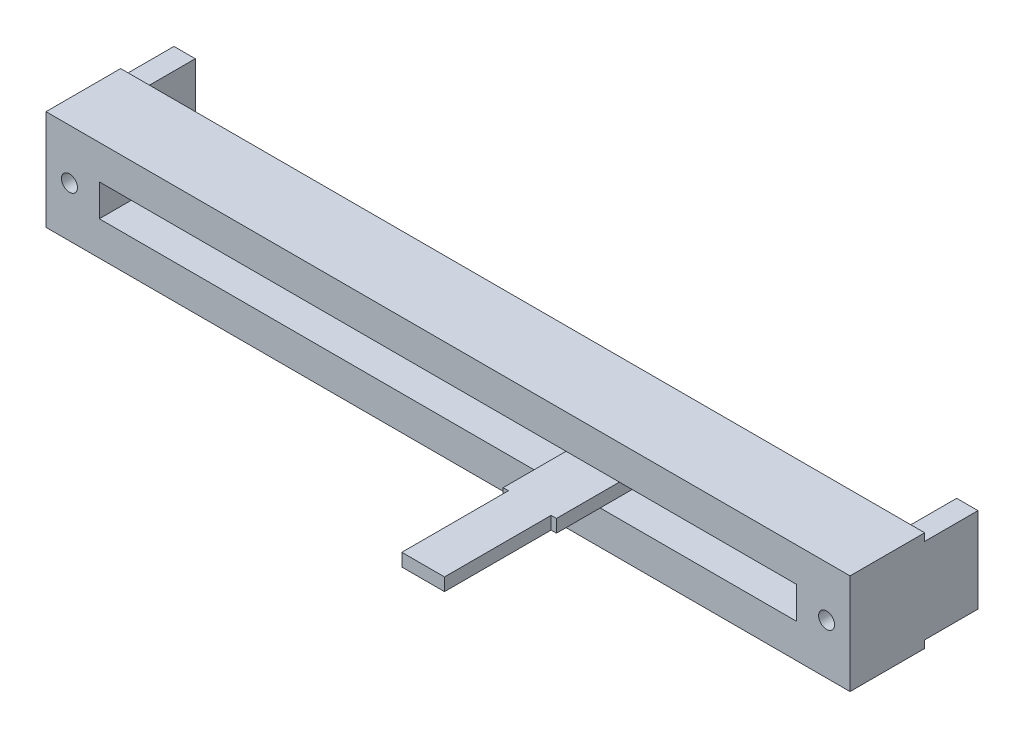
from build123d import *

# Parameters (mm, degrees)
SKETCH1_W           = 75.4
SKETCH1_H           = 9.4
BOSS_EXTRUDE1_DEPTH = 7
SKETCH2_R           = 0.75
SKETCH2_W           = 65.4
SKETCH2_H           = 3
CUT_EXTRUDE1_DEPTH  = 5
SKETCH3_W           = 2
SKETCH3_H           = 8
BOSS_EXTRUDE2_DEPTH = 5
BOSS_EXTRUDE3_DEPTH = 0.6


with BuildPart() as part:
    # Sketch1 → Boss-Extrude1 (new body)
    with BuildSketch(Plane.XY):
        Rectangle(SKETCH1_W, SKETCH1_H)
    extrude(amount=BOSS_EXTRUDE1_DEPTH)

    # Sketch2 → Cut-Extrude1 (cut)
    with BuildSketch(Plane.XY.offset(7)):
        with Locations((-35.5, 0)):
            Circle(SKETCH2_R)
        with Locations((35.5, 0)):
            Circle(SKETCH2_R)
        Rectangle(SKETCH2_W, SKETCH2_H)
    extrude(amount=-CUT_EXTRUDE1_DEPTH, mode=Mode.SUBTRACT)

    # Sketch3 → Boss-Extrude2 (add)
    with BuildSketch(Plane(origin=(0, 0, 0), x_dir=(-1, 0, 0), z_dir=(0, 0, -1))):
        with Locations((-36.7, 0)):
            Rectangle(SKETCH3_W, SKETCH3_H)
        with Locations((36.7, 0)):
            Rectangle(SKETCH3_W, SKETCH3_H)
    extrude(amount=BOSS_EXTRUDE2_DEPTH)

    # Sketch4 → Boss-Extrude3 (add, symmetric)
    with BuildSketch(Plane(origin=(0, 0, 0), x_dir=(1, 0, 0), z_dir=(0, 1, 0))):
        Polygon((10.169323516, 0), (15.169323516, 0), (15.169323516, -12), (14.669323516, -12), (14.669323516, -22), (10.669323516, -22), (10.669323516, -12), (10.169323516, -12), align=None)
    extrude(amount=BOSS_EXTRUDE3_DEPTH, both=True)


solid = part.part
